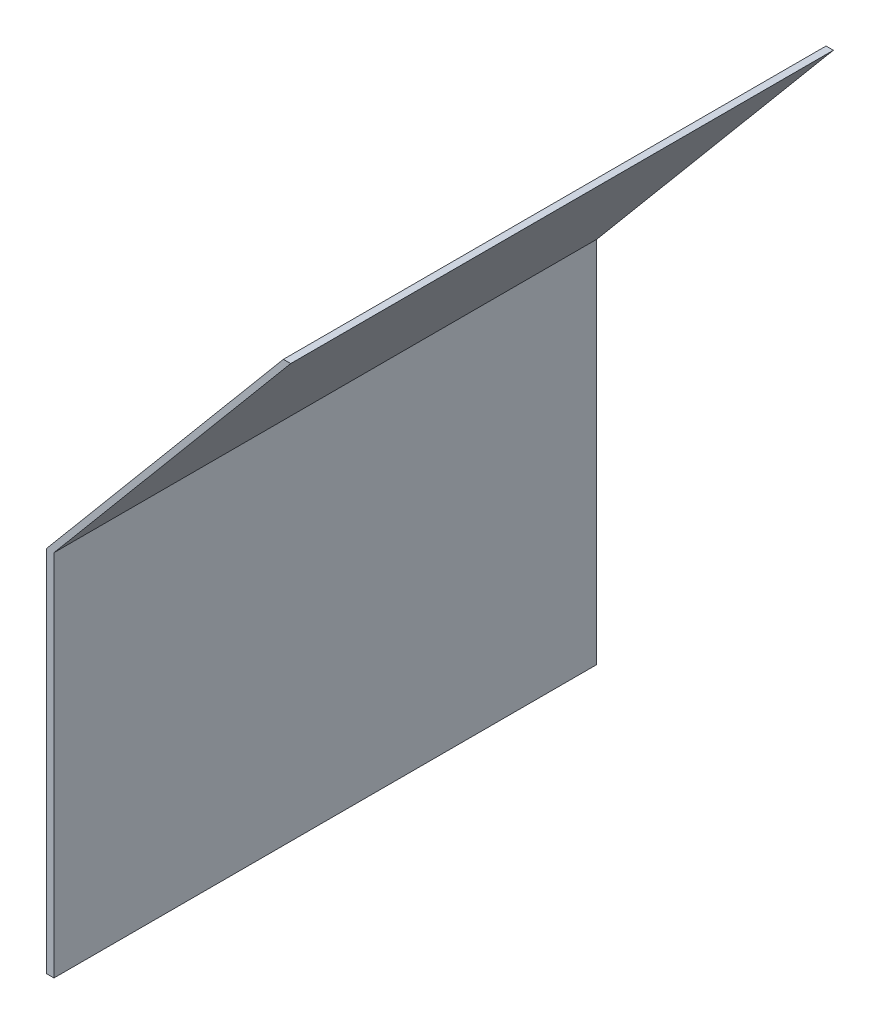
from build123d import *

# Parameters (mm, degrees)
BOSS_EXTRUDE1_DEPTH = 112.268


with BuildPart() as part:
    # Sketch1 → Boss-Extrude1 (new body)
    with BuildSketch(Plane.XY):
        Polygon((0, 0), (1.51892, 0), (1.51892, 76.2), (50.499335858, 134.572586566), (48.980415858, 134.572586566), (0, 76.2), align=None)
    extrude(amount=BOSS_EXTRUDE1_DEPTH)


solid = part.part
